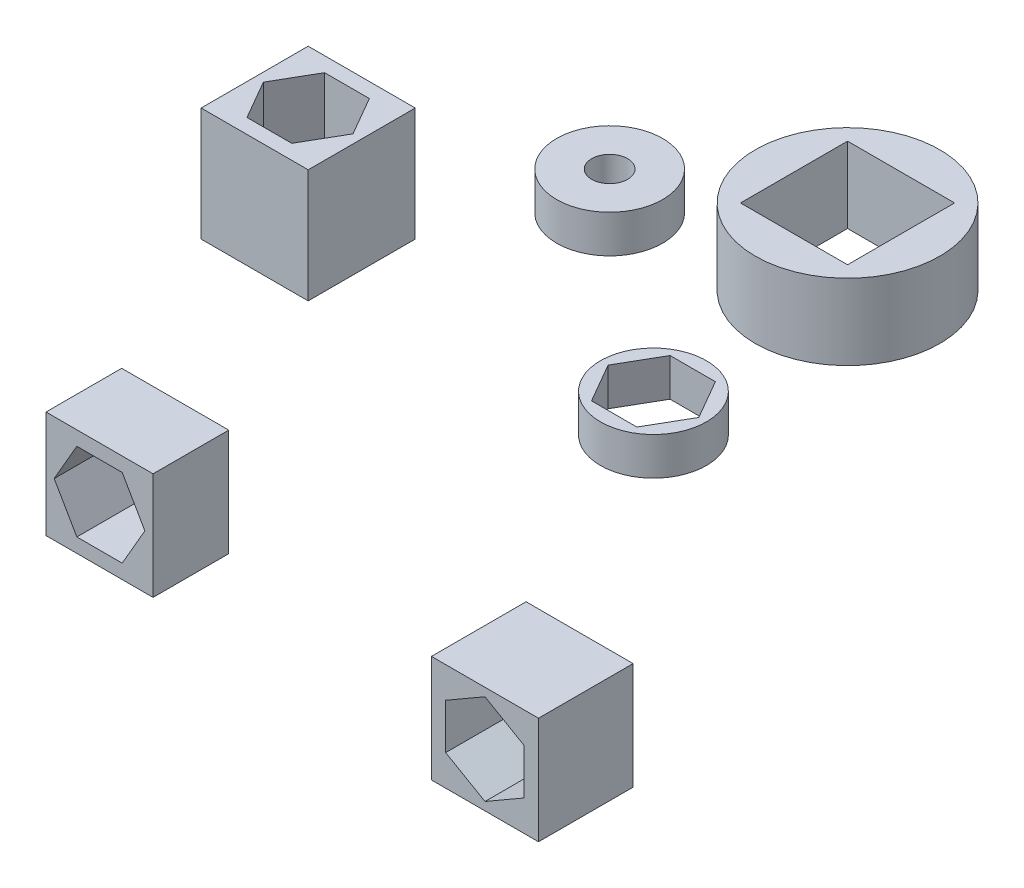
from build123d import *

# Parameters (mm, degrees)
SKETCH_1_R          = 2.8
EXTRUDE_1_DEPTH     = 6
SKETCH_1_R_2        = 0.95
EXTRUDE_1_2_DEPTH   = 6
SKETCH_1_W          = 5.656854249
SKETCH_1_H          = 5.65685425
EXTRUDE_1_3_DEPTH   = 6
SKETCH_2_R          = 2.8
CUT_EXTRUDE_1_DEPTH = 4
SKETCH_3_R          = 2.8
CUT_EXTRUDE_2_DEPTH = 4
SKETCH_4_R          = 4.875
SKETCH_4_W          = 5.656854249
SKETCH_4_H          = 5.656854249
EXTRUDE_2_DEPTH     = 4
SKETCH_7_W          = 5.65685425
SKETCH_7_H          = 5.656854249
EXTRUDE_3_DEPTH     = 4
CUT_EXTRUDE_3_DEPTH = 4
SKETCH_6_W          = 5.65685425
SKETCH_6_H          = 5.656854249
EXTRUDE_4_DEPTH     = 4
SKETCH_9_R          = 4.757341929
CUT_EXTRUDE_4_DEPTH = 4
SKETCH_15_W         = 9.812239566
SKETCH_15_H         = 9.127664712
EXTRUDE_5_DEPTH     = 4
CUT_EXTRUDE_5_DEPTH = 4
SKETCH_16_W         = 5.65685425
SKETCH_16_H         = 5.656854249
EXTRUDE_6_DEPTH     = 5


with BuildPart() as part:
    # 草图1 → 凸台-拉伸1 (new body)
    with BuildSketch(Plane(origin=(0, 0, 0), x_dir=(1, 0, 0), z_dir=(0, 1, 0))):
        with Locations((-34.760304923, 16.654905742)):
            Circle(SKETCH_1_R)
        Polygon((-32.364301306, 16.654905742), (-33.562303115, 18.729905742), (-35.958306732, 18.729905742), (-37.156308541, 16.654905742), (-35.958306732, 14.579905742), (-33.562303115, 14.579905742), align=None, mode=Mode.SUBTRACT)
    extrude(amount=EXTRUDE_1_DEPTH)

    # 草图3 → 切除-拉伸2 (cut)
    with BuildSketch(Plane(origin=(0, 6, 0), x_dir=(1, 0, 0), z_dir=(0, 1, 0))):
        with Locations((-34.760304923, 16.654905742)):
            Circle(SKETCH_3_R)
    extrude(amount=-CUT_EXTRUDE_2_DEPTH, mode=Mode.SUBTRACT)


with BuildPart() as body_2:
    # 草图1 → Extrude 1 2 (new body)
    with BuildSketch(Plane(origin=(0, 0, 0), x_dir=(1, 0, 0), z_dir=(0, 1, 0))):
        with Locations((-46.089532079, 25.669899162)):
            Circle(SKETCH_1_R)
        with Locations((-46.089532079, 25.669899162)):
            Circle(SKETCH_1_R_2, mode=Mode.SUBTRACT)
    extrude(amount=EXTRUDE_1_2_DEPTH)

    # 草图2 → 切除-拉伸1 (cut)
    with BuildSketch(Plane(origin=(0, 6, 0), x_dir=(1, 0, 0), z_dir=(0, 1, 0))):
        with Locations((-46.089532079, 25.669899162)):
            Circle(SKETCH_2_R)
    extrude(amount=-CUT_EXTRUDE_1_DEPTH, mode=Mode.SUBTRACT)


with BuildPart() as body_3:
    # 草图1 → Extrude 1 3 (new body)
    with BuildSketch(Plane(origin=(0, 0, 0), x_dir=(1, 0, 0), z_dir=(0, 1, 0))):
        with Locations((-52.84621627, 16.49589495)):
            Rectangle(SKETCH_1_W, SKETCH_1_H)
        Polygon((-50.479080166, 16.49589495), (-51.662648218, 18.54589495), (-54.029784321, 18.54589495), (-55.213352373, 16.49589495), (-54.029784321, 14.44589495), (-51.662648218, 14.44589495), align=None, mode=Mode.SUBTRACT)
    extrude(amount=EXTRUDE_1_3_DEPTH)


with BuildPart() as body_4:
    # 草图4 → 凸台-拉伸2 (new body)
    with BuildSketch(Plane(origin=(0, 0, 0), x_dir=(1, 0, 0), z_dir=(0, 1, 0))):
        with Locations((-36.250063578, 28.401181635)):
            Circle(SKETCH_4_R)
        with Locations((-36.250063578, 28.401181635)):
            Rectangle(SKETCH_4_W, SKETCH_4_H, mode=Mode.SUBTRACT)
    extrude(amount=EXTRUDE_2_DEPTH)


with BuildPart() as body_5:
    # 草图7 → 凸台-拉伸3 (new body)
    with BuildSketch(Plane.XY):
        with Locations((-43.376183392, 2.828427125)):
            Rectangle(SKETCH_7_W, SKETCH_7_H)
    extrude(amount=EXTRUDE_3_DEPTH)

    # 草图8 → 切除-拉伸3 (cut)
    with BuildSketch(Plane.XY.offset(4)):
        Polygon((-40.980179775, 2.828427125), (-42.178181584, 4.903427125), (-44.574185201, 4.903427125), (-45.772187009, 2.828427125), (-44.574185201, 0.753427125), (-42.178181584, 0.753427125), align=None)
    extrude(amount=-CUT_EXTRUDE_3_DEPTH, mode=Mode.SUBTRACT)


with BuildPart() as body_6:
    # 草图6 → 凸台-拉伸4 (new body)
    with BuildSketch(Plane(origin=(0, 0, 0), x_dir=(1, 0, 0), z_dir=(0, 1, 0))):
        with Locations((-43.376183392, 17.525126096)):
            Rectangle(SKETCH_6_W, SKETCH_6_H)
    extrude(amount=EXTRUDE_4_DEPTH)

    # 草图9 → 切除-拉伸4 (cut)
    with BuildSketch(Plane(origin=(0, 4, 0), x_dir=(1, 0, 0), z_dir=(0, 1, 0))):
        with Locations((-43.450707385, 17.511400193)):
            Circle(SKETCH_9_R)
    extrude(amount=-CUT_EXTRUDE_4_DEPTH, mode=Mode.SUBTRACT)


with BuildPart() as body_6_2:
    # 草图15 → 凸台-拉伸5 (new body)
    with BuildSketch(Plane(origin=(0, 0, 0), x_dir=(1, 0, 0), z_dir=(0, 1, 0))):
        with Locations((-19.930146637, 14.162247717)):
            Rectangle(SKETCH_15_W, SKETCH_15_H)
    extrude(amount=EXTRUDE_5_DEPTH)

    # 草图17 → 切除-拉伸5 (cut)
    with BuildSketch(Plane(origin=(0, 4, 0), x_dir=(1, 0, 0), z_dir=(0, 1, 0))):
        Polygon((-26.76182384, 19.295189445), (-26.76182384, 9.470114101), (-13.070399402, 9.470114101), (-13.434291082, 20.705269703), align=None)
    extrude(amount=-CUT_EXTRUDE_5_DEPTH, mode=Mode.SUBTRACT)


with BuildPart() as body_6_3:
    # 草图16 → 凸台-拉伸6 (new body)
    with BuildSketch(Plane.XY):
        with Locations((-22.007839295, 2.828427125)):
            Rectangle(SKETCH_16_W, SKETCH_16_H)
        Polygon((-22.007839295, 5.224430742), (-24.082839295, 4.026428933), (-24.082839295, 1.630425316), (-22.007839295, 0.432423508), (-19.932839295, 1.630425316), (-19.932839295, 4.026428933), align=None, mode=Mode.SUBTRACT)
    extrude(amount=EXTRUDE_6_DEPTH)


solid = Compound([part.part, body_2.part, body_3.part, body_4.part, body_5.part, body_6_3.part])
